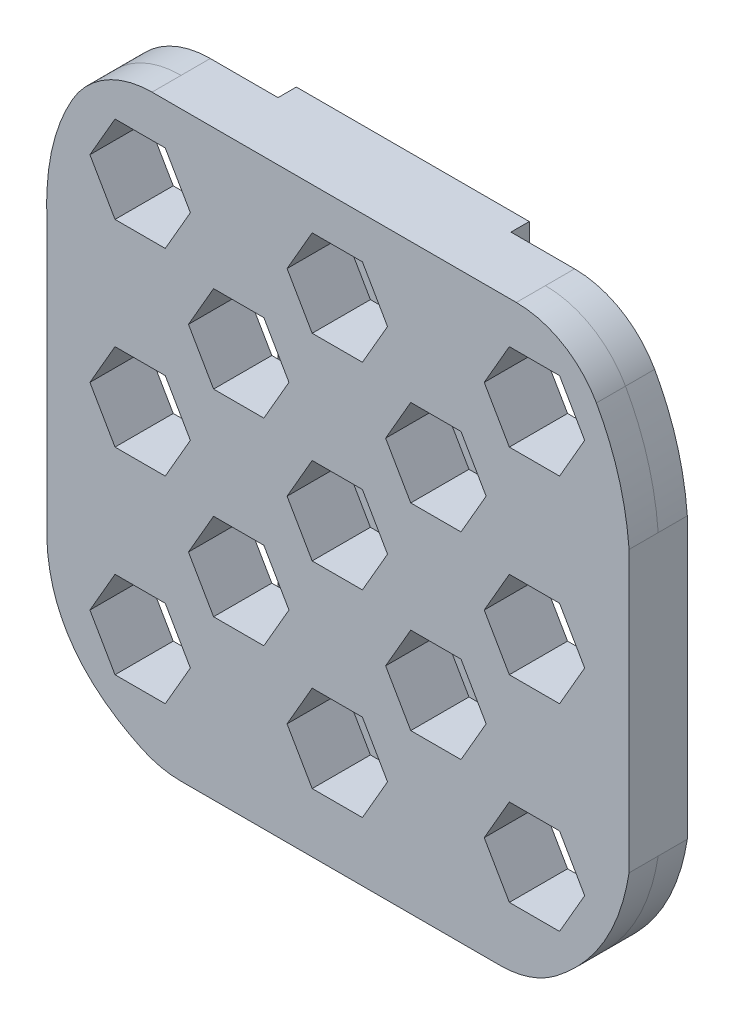
from build123d import *

# Parameters (mm, degrees)
BOSS_EXTRUDE1_DEPTH = 3.175
BOSS_EXTRUDE2_DEPTH = 3.175
SKETCH2_W           = 12.7
SKETCH2_H           = 63.5
BOSS_EXTRUDE3_DEPTH = 2
CUT_EXTRUDE1_DEPTH  = 6.35
FILLET1_R           = 10


with BuildPart() as part:
    # Sketch1 → Boss-Extrude1 (new body)
    with BuildSketch(Plane.XY):
        with BuildLine():
            Line((12.586143856, 0), (52.341618497, 0))
            add(Edge.make_bspline(
                [(63.5, 15.783236994), (61.818196066, 5.163888879), (52.341618497, 0)],
                knots=[0, 0, 0, 1, 1, 1], degree=2))
            Line((63.5, 15.783236994), (63.5, 46.321965318))
            add(Edge.make_bspline(
                [(63.5, 46.321965318), (62.735953046, 56.152543933), (56.305780347, 63.5)],
                knots=[0, 0, 0, 1, 1, 1], degree=2))
            Line((56.305780347, 63.5), (6.82716763, 63.5))
            add(Edge.make_bspline(
                [(0, 46.321965318), (-0.299080934, 56.868733054), (6.82716763, 63.5)],
                knots=[0, 0, 0, 1, 1, 1], degree=2))
            Line((0, 46.321965318), (0, 15.783236994))
            add(Edge.make_bspline(
                [(0, 15.783236994), (0.304891955, 4.651584914), (12.586143856, 0)],
                knots=[0, 0, 0, 1, 1, 1], degree=2))
        make_face()
    extrude(amount=BOSS_EXTRUDE1_DEPTH)

    # Sketch3 → Boss-Extrude2 (add)
    with BuildSketch(Plane.XY.offset(3.175)):
        with BuildLine():
            Line((12.586143857, -1e-09), (52.341618497, 0))
            add(Edge.make_bspline(
                [(52.341618497, 0), (61.818196066, 5.163888879), (63.5, 15.783236995)],
                knots=[0, 0, 0, 1, 1, 1], degree=2))
            Line((63.5, 15.783236995), (63.5, 46.321965318))
            add(Edge.make_bspline(
                [(63.5, 46.321965318), (62.735953046, 56.152543933), (56.305780347, 63.5)],
                knots=[0, 0, 0, 1, 1, 1], degree=2))
            Line((56.305780347, 63.5), (6.82716763, 63.5))
            add(Edge.make_bspline(
                [(6.82716763, 63.5), (-0.299080929, 56.868733059), (0, 46.321965333)],
                knots=[0, 0, 0, 1, 1, 1], degree=2))
            Line((0, 46.321965333), (-2e-09, 15.783237047))
            add(Edge.make_bspline(
                [(-2e-09, 15.783237047), (0.304891926, 4.651584925), (12.586143857, -1e-09)],
                knots=[0, 0, 0, 1, 1, 1], degree=2))
        make_face()
    extrude(amount=BOSS_EXTRUDE2_DEPTH)

    # Sketch2 → Boss-Extrude3 (add)
    with BuildSketch(Plane(origin=(0, 0, 0), x_dir=(-1, 0, 0), z_dir=(0, 0, -1))):
        with Locations((-25.216473988, 31.75)):
            Rectangle(SKETCH2_W, SKETCH2_H)
        with Locations((-37.916473988, 31.75)):
            Rectangle(SKETCH2_W, SKETCH2_H)
    extrude(amount=BOSS_EXTRUDE3_DEPTH)

    # Sketch4 → Cut-Extrude1 (cut)
    with BuildSketch(Plane.XY.offset(6.35)):
        Polygon((47.703064377, 54.201225123), (50.44178546, 49.457621059), (55.919227626, 49.457621059), (58.657948709, 54.201225123), (55.919227626, 58.944829186), (50.44178546, 58.944829186), align=None)
        Polygon((36.950506543, 43.554276624), (39.690506543, 38.808457411), (45.170506543, 38.808457411), (47.910506543, 43.554276624), (45.170506543, 48.300095837), (39.690506543, 48.300095837), align=None)
        Polygon((47.703064377, 32.701225123), (50.44178546, 27.957621059), (55.919227626, 27.957621059), (58.657948709, 32.701225123), (55.919227626, 37.444829186), (50.44178546, 37.444829186), align=None)
        Polygon((36.950506543, 22.054276624), (39.690506543, 17.308457411), (45.170506543, 17.308457411), (47.910506543, 22.054276624), (45.170506543, 26.800095837), (39.690506543, 26.800095837), align=None)
        Polygon((47.703064377, 11.201225123), (50.44178546, 6.457621059), (55.919227626, 6.457621059), (58.657948709, 11.201225123), (55.919227626, 15.944829186), (50.44178546, 15.944829186), align=None)
        Polygon((26.203064377, 11.201225123), (28.94178546, 6.457621059), (34.419227626, 6.457621059), (37.157948709, 11.201225123), (34.419227626, 15.944829186), (28.94178546, 15.944829186), align=None)
        Polygon((26.203064377, 32.701225123), (28.94178546, 27.957621059), (34.419227626, 27.957621059), (37.157948709, 32.701225123), (34.419227626, 37.444829186), (28.94178546, 37.444829186), align=None)
        Polygon((26.203064377, 54.201225123), (28.94178546, 49.457621059), (34.419227626, 49.457621059), (37.157948709, 54.201225123), (34.419227626, 58.944829186), (28.94178546, 58.944829186), align=None)
        Polygon((15.450506543, 43.554276624), (18.190506543, 38.808457411), (23.670506543, 38.808457411), (26.410506543, 43.554276624), (23.670506543, 48.300095837), (18.190506543, 48.300095837), align=None)
        Polygon((4.703064377, 54.201225123), (7.44178546, 49.457621059), (12.919227626, 49.457621059), (15.657948709, 54.201225123), (12.919227626, 58.944829186), (7.44178546, 58.944829186), align=None)
        Polygon((4.703064377, 32.701225123), (7.44178546, 27.957621059), (12.919227626, 27.957621059), (15.657948709, 32.701225123), (12.919227626, 37.444829186), (7.44178546, 37.444829186), align=None)
        Polygon((15.450506543, 22.054276624), (18.190506543, 17.308457411), (23.670506543, 17.308457411), (26.410506543, 22.054276624), (23.670506543, 26.800095837), (18.190506543, 26.800095837), align=None)
        Polygon((4.703064377, 11.201225123), (7.44178546, 6.457621059), (12.919227626, 6.457621059), (15.657948709, 11.201225123), (12.919227626, 15.944829186), (7.44178546, 15.944829186), align=None)
    extrude(amount=-CUT_EXTRUDE1_DEPTH, mode=Mode.SUBTRACT)

    # Fillet1
    fillet1_edges = [part.edges().sort_by_distance(p)[0] for p in [
        (56.305780347, 63.5, 4.7625),
        (52.341618497, 0, 1.5875),
        (12.586143856, 0, 1.5875),
        (6.82716763, 63.5, 4.7625),
        (56.305780347, 63.5, 1.5875),
        (52.341618497, 0, 4.7625),
        (12.586143857, -1e-09, 4.7625),
        (6.82716763, 63.5, 1.5875),
    ]]
    fillet(fillet1_edges, radius=FILLET1_R)


solid = part.part
